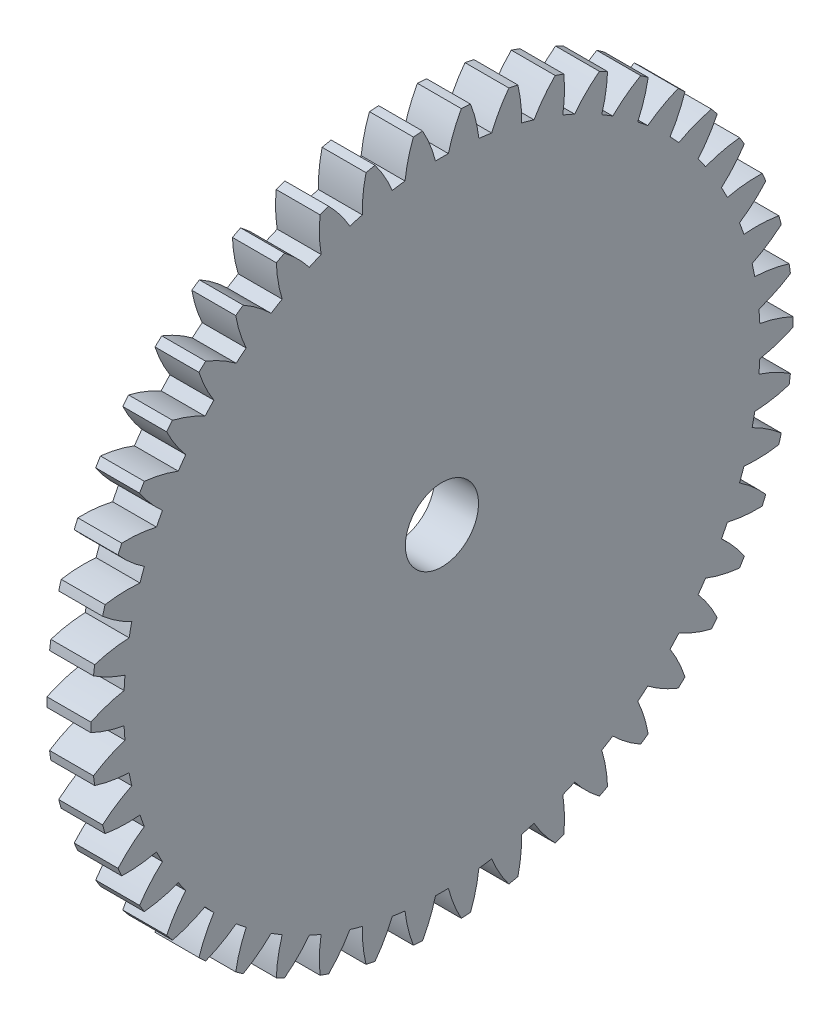
from build123d import *

# Parameters (mm, degrees)
BASPROSKE_W     = 3
BASPROSKE_H     = 24
TOOTHCUT_DEPTH  = 35.073450075
TEETHCUTS_COUNT = 46
TEETHCUTS_ANGLE = 352.173913043
BORSKE_R        = 2.5
BORE_DEPTH      = 50.0000508


with BuildPart() as part:
    # BasProSke → Base-Revolve (revolve)
    with BuildSketch(Plane(origin=(0, 0, 0), x_dir=(1, 0, 0), z_dir=(0, 1, 0)), mode=Mode.PRIVATE) as base_revolve_sk:
        with Locations((1.5, 12)):
            Rectangle(BASPROSKE_W, BASPROSKE_H)
    revolve(base_revolve_sk.sketch.rotate(Axis((-10, 0, 0), (1, 0, 0)), 180), axis=Axis((-10, 0, 0), (1, 0, 0)))

    # TooCutSke → ToothCut (cut, through all)
    with BuildSketch(Plane(origin=(0, 0, 0), x_dir=(0, 0, -1), z_dir=(1, 0, 0))):
        with BuildLine():
            ThreePointArc((0.441526923, 21.744517814), (0, 21.749), (-0.441526923, 21.744517814))
            ThreePointArc((-0.441526923, 21.744517814), (-0.815896613, 22.895874179), (-1.338211282, 23.988101962))
            ThreePointArc((-1.338211282, 23.988101962), (0, 24.0254), (1.338211282, 23.988101962))
            ThreePointArc((1.338211282, 23.988101962), (0.815896613, 22.895874179), (0.441526923, 21.744517814))
        make_face()
    toothcut = extrude(amount=TOOTHCUT_DEPTH, mode=Mode.SUBTRACT)

    # TeethCuts: ToothCut ×46 about axis
    teethcuts_axis = Axis((-10, 0, 0), (1, 0, 0))
    for i in range(1, TEETHCUTS_COUNT):
        add(toothcut.rotate(teethcuts_axis, i * TEETHCUTS_ANGLE / (TEETHCUTS_COUNT - 1)), mode=Mode.SUBTRACT)

    # BorSke → Bore (cut, symmetric)
    with BuildSketch(Plane(origin=(0, 0, 0), x_dir=(0, 0, -1), z_dir=(1, 0, 0))):
        with Locations(Location((0, 0, 0), (0, 0, 180))):
            Circle(BORSKE_R)
    extrude(amount=BORE_DEPTH, both=True, mode=Mode.SUBTRACT)


solid = part.part
